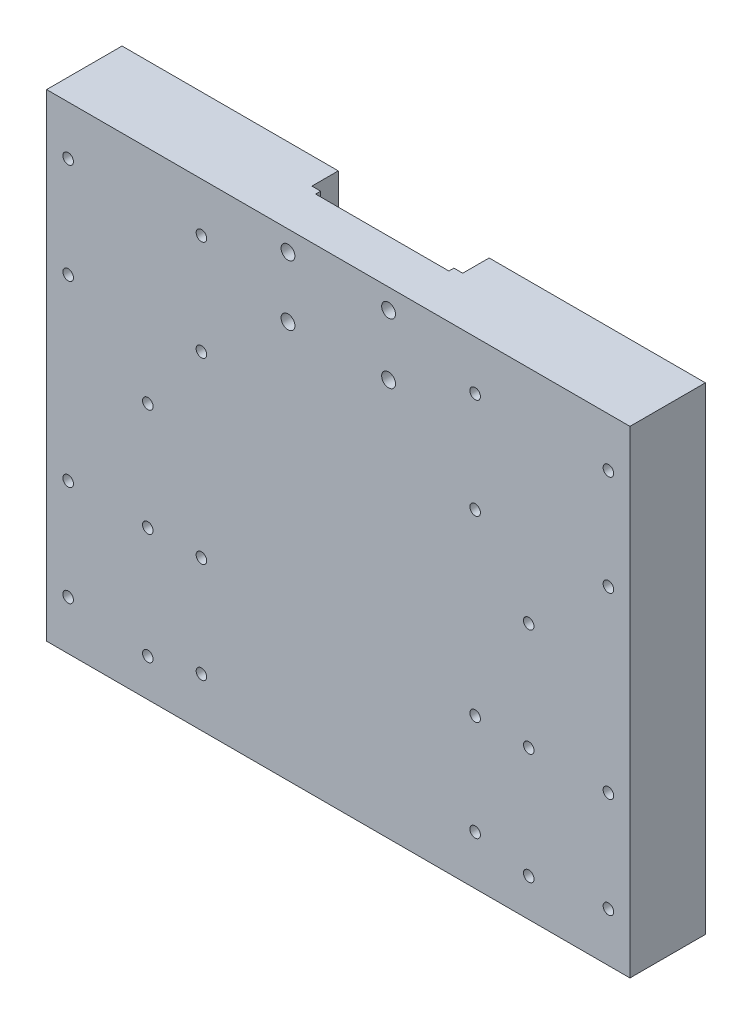
from build123d import *

# Parameters (mm, degrees)
SCHIZZO1_W                   = 232
SCHIZZO1_H                   = 190
ESTRUSIONE_ESTRUSIONE1_DEPTH = 30
SCHIZZO4_W                   = 60
SCHIZZO4_H                   = 10.5
TAGLIO_ESTRUSIONE2_DEPTH     = 191
TAP_DRILL_FOR_M5_TAP1_D      = 4.2
M5_CLEARANCE_HOLE1_D         = 5.5
TAP_DRILL_FOR_M5_TAP3_D      = 4.2
TAP_DRILL_FOR_M5_TAP3_DEPTH  = 30
SKETCH8_W                    = 53
SKETCH8_H                    = 52
CUT_EXTRUDE1_DEPTH           = 2


with BuildPart() as part:
    # Schizzo1 → Estrusione-Estrusione1 (new body)
    with BuildSketch(Plane.XY):
        Rectangle(SCHIZZO1_W, SCHIZZO1_H)
    extrude(amount=ESTRUSIONE_ESTRUSIONE1_DEPTH)

    # Schizzo4 → Taglio-Estrusione2 (cut, through all)
    with BuildSketch(Plane(origin=(0, 95, 0), x_dir=(1, 0, 0), z_dir=(0, 1, 0))):
        with Locations((0, -5.25)):
            Rectangle(SCHIZZO4_W, SCHIZZO4_H)
    extrude(amount=-TAGLIO_ESTRUSIONE2_DEPTH, mode=Mode.SUBTRACT)

    # Tap Drill for M5 Tap1 (through all)
    with Locations(Plane(origin=(0, 0, 0), x_dir=(-1, 0, 0), z_dir=(0, 0, -1))):
        with Locations((-54.428761817, 35.5), (-54.428761817, 75.5), (-107.428761817, 35.5), (-107.428761817, -75.5), (-107.428761817, -35.5), (-54.428761817, -35.5), (-54.428761817, -75.5), (54.428761817, -75.5), (54.428761817, -35.5), (107.428761817, -35.5), (107.428761817, -75.5), (107.428761817, 75.5), (107.428761817, 35.5), (54.428761817, 35.5), (54.428761817, 75.5), (-107.428761817, 75.5)):
            Hole(TAP_DRILL_FOR_M5_TAP1_D / 2)

    # M5 Clearance Hole1 (through all)
    with Locations(Plane.XY.offset(30)):
        with Locations((-20, 87), (20, 87), (20, 63), (-20, 63)):
            Hole(M5_CLEARANCE_HOLE1_D / 2)

    # Tap Drill for M5 Tap3
    with Locations(Plane.XY.offset(30)):
        with Locations((-75.75, 7), (-75.75, -80), (75.75, 7), (75.75, -80), (-75.75, -35.79251315), (75.75, -35.79251315)):
            Hole(TAP_DRILL_FOR_M5_TAP3_D / 2, depth=TAP_DRILL_FOR_M5_TAP3_DEPTH)

    # Sketch8 → Cut-Extrude1 (cut)
    with BuildSketch(Plane(origin=(0, 0, 10.5), x_dir=(-1, 0, 0), z_dir=(0, 0, -1))):
        with Locations((0, 69)):
            Rectangle(SKETCH8_W, SKETCH8_H)
    extrude(amount=-CUT_EXTRUDE1_DEPTH, mode=Mode.SUBTRACT)


solid = part.part
